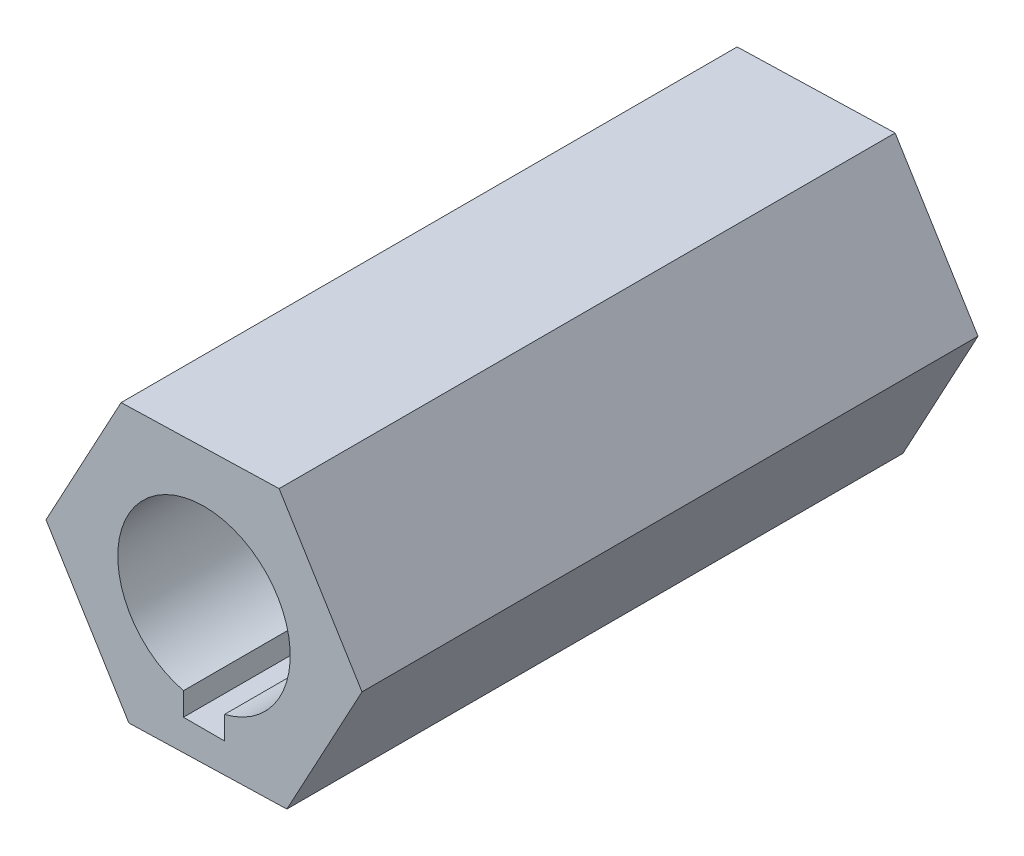
from build123d import *

# Parameters (mm, degrees)
SKETCH1_R           = 4
BOSS_EXTRUDE1_DEPTH = 28.575
SKETCH2_W           = 1.905
SKETCH2_H           = 1.905
CUT_EXTRUDE1_DEPTH  = 29.575


with BuildPart() as part:
    # Sketch1 → Boss-Extrude1 (new body)
    with BuildSketch(Plane.XY):
        Polygon((-7.329405666, -0.20771595), (-3.484815544, -6.451309476), (3.844590123, -6.243593526), (7.329405666, 0.20771595), (3.484815544, 6.451309476), (-3.844590123, 6.243593526), align=None)
        Circle(SKETCH1_R, mode=Mode.SUBTRACT)
    extrude(amount=BOSS_EXTRUDE1_DEPTH)

    # Sketch2 → Cut-Extrude1 (cut, through all)
    with BuildSketch(Plane.XY.offset(28.575)):
        with Locations((0, -4)):
            Rectangle(SKETCH2_W, SKETCH2_H)
    extrude(amount=-CUT_EXTRUDE1_DEPTH, mode=Mode.SUBTRACT)


solid = part.part
